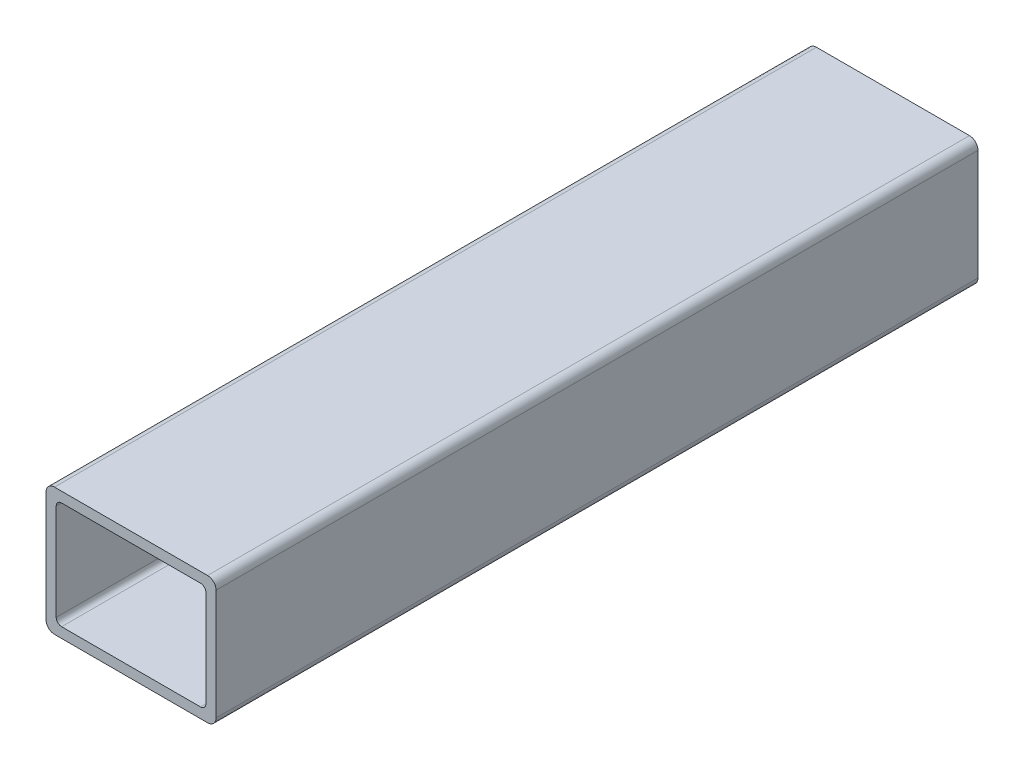
from build123d import *

# Parameters (mm, degrees)
BOSS_EXTRUDE1_DEPTH = 227.56368


with BuildPart() as part:
    # Sketch4 → Boss-Extrude1 (new body)
    with BuildSketch(Plane.XY):
        with BuildLine():
            Line((25.4, -16.51), (25.4, 16.51))
            ThreePointArc((25.4, 16.51), (24.656051224, 18.306051224), (22.86, 19.05))
            Line((22.86, 19.05), (-22.86, 19.05))
            ThreePointArc((-22.86, 19.05), (-24.656051224, 18.306051224), (-25.4, 16.51))
            Line((-25.4, 16.51), (-25.4, -16.51))
            ThreePointArc((-25.4, -16.51), (-24.656051224, -18.306051224), (-22.86, -19.05))
            Line((-22.86, -19.05), (22.86, -19.05))
            ThreePointArc((22.86, -19.05), (24.656051224, -18.306051224), (25.4, -16.51))
        make_face()
        with BuildLine():
            Line((22.352, 14.4018), (22.352, -14.4018))
            ThreePointArc((22.352, -14.4018), (21.883312271, -15.533312271), (20.7518, -16.002))
            Line((20.7518, -16.002), (-20.7518, -16.002))
            ThreePointArc((-20.7518, -16.002), (-21.883312271, -15.533312271), (-22.352, -14.4018))
            Line((-22.352, -14.4018), (-22.352, 14.4018))
            ThreePointArc((-22.352, 14.4018), (-21.883312271, 15.533312271), (-20.7518, 16.002))
            Line((-20.7518, 16.002), (20.7518, 16.002))
            ThreePointArc((20.7518, 16.002), (21.883312271, 15.533312271), (22.352, 14.4018))
        make_face(mode=Mode.SUBTRACT)
    extrude(amount=BOSS_EXTRUDE1_DEPTH)


solid = part.part
